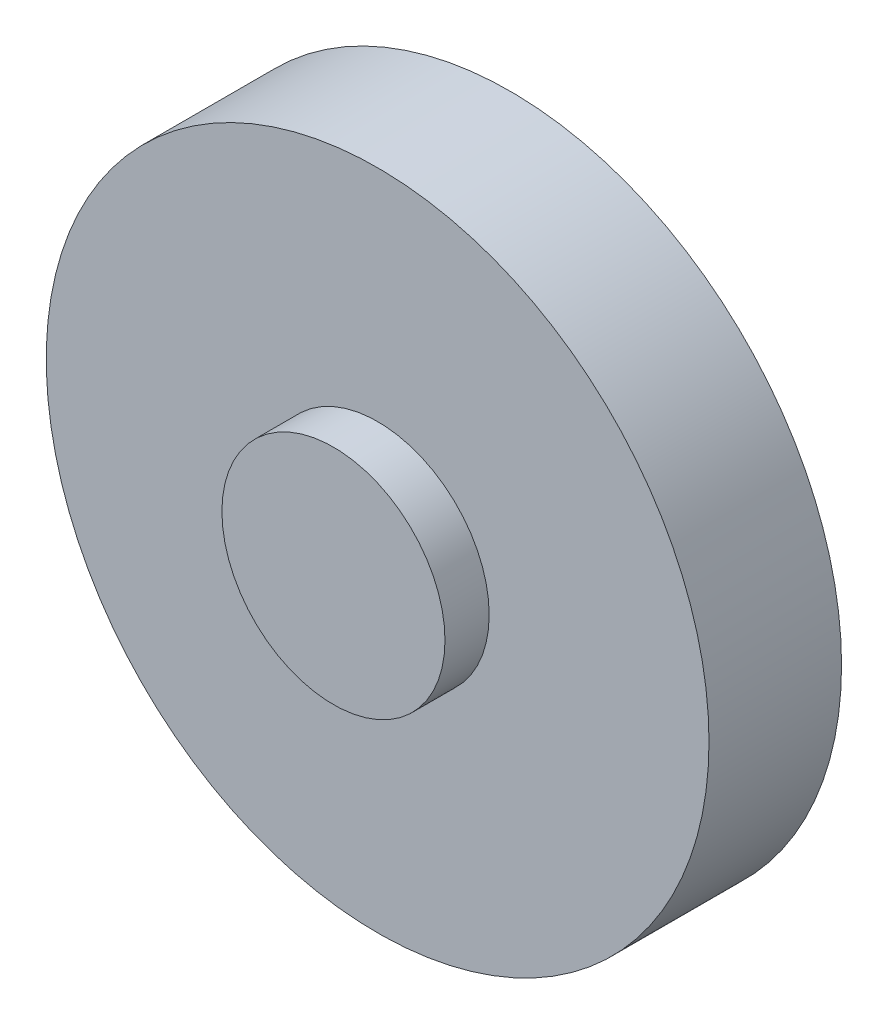
from build123d import *

# Parameters (mm, degrees)
SKETCH1_R           = 150
BOSS_EXTRUDE1_DEPTH = 60
SKETCH2_R           = 50.492278984
BOSS_EXTRUDE2_DEPTH = 20
SKETCH3_R           = 49.346148261
BOSS_EXTRUDE3_DEPTH = 20


with BuildPart() as part:
    # Sketch1 → Boss-Extrude1 (new body)
    with BuildSketch(Plane.XY):
        Circle(SKETCH1_R)
    extrude(amount=BOSS_EXTRUDE1_DEPTH)

    # Sketch2 → Boss-Extrude2 (add)
    with BuildSketch(Plane.XY.offset(60)):
        Circle(SKETCH2_R)
    extrude(amount=BOSS_EXTRUDE2_DEPTH)

    # Sketch3 → Boss-Extrude3 (add)
    with BuildSketch(Plane(origin=(0, 0, 0), x_dir=(-1, 0, 0), z_dir=(0, 0, -1))):
        Circle(SKETCH3_R)
    extrude(amount=BOSS_EXTRUDE3_DEPTH)


solid = part.part
